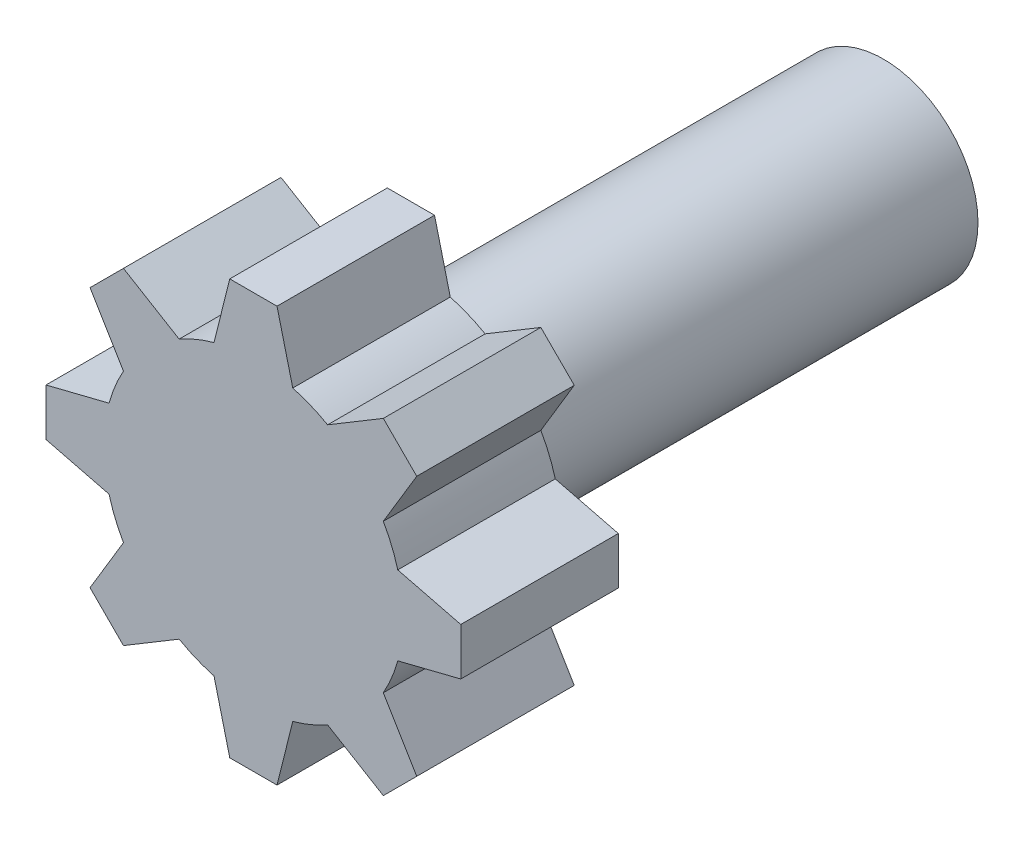
from build123d import *

# Parameters (mm, degrees)
ESQUISSE1_R                  = 4.75
MAIN_EXTRUSION_DEPTH         = 5
GEAR_ELEMENT_DEPTH           = 5
R_P_TITION_CIRCULAIRE1_COUNT = 8
ESQUISSE3_R                  = 3
MAIN_AXE_DEPTH               = 15
ESQUISSE4_W                  = 4
ESQUISSE4_H                  = 1
AXE_TRAIT_DEPTH              = 3


with BuildPart() as part:
    # Esquisse1 → Main Extrusion (new body)
    with BuildSketch(Plane.XY):
        Circle(ESQUISSE1_R)
    extrude(amount=MAIN_EXTRUSION_DEPTH)

    # Esquisse2 → Gear Element (add)
    with BuildSketch(Plane.XY.offset(5)):
        Polygon((-1.25, 4.582575695), (1.25, 4.582575695), (0.75, 6.582575695), (-0.75, 6.582575695), align=None)
    gear_element = extrude(amount=-GEAR_ELEMENT_DEPTH)

    # Répétition circulaire1: Gear Element ×8 about axis
    r_p_tition_circulaire1_axis = Axis((0, 0, 0), (0, 0, 1))
    for i in range(1, R_P_TITION_CIRCULAIRE1_COUNT):
        add(gear_element.rotate(r_p_tition_circulaire1_axis, i * 360 / R_P_TITION_CIRCULAIRE1_COUNT))

    # Esquisse3 → Main Axe (add)
    with BuildSketch(Plane(origin=(0, 0, 0), x_dir=(-1, 0, 0), z_dir=(0, 0, -1))):
        Circle(ESQUISSE3_R)
    extrude(amount=MAIN_AXE_DEPTH)

    # Esquisse4 → Axe Trait (cut)
    with BuildSketch(Plane(origin=(0, 0, -15), x_dir=(-1, 0, 0), z_dir=(0, 0, -1))):
        Rectangle(ESQUISSE4_W, ESQUISSE4_H)
    extrude(amount=-AXE_TRAIT_DEPTH, mode=Mode.SUBTRACT)


solid = part.part
